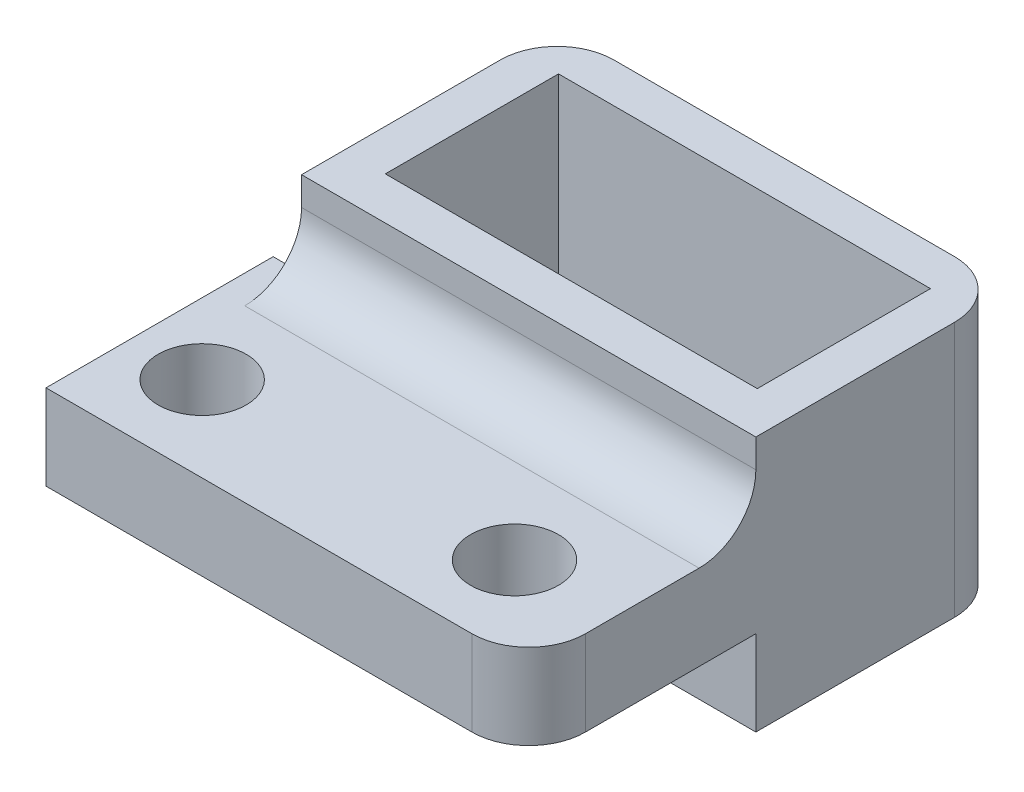
from build123d import *

# Parameters (mm, degrees)
CROQUIS1_W              = 18
CROQUIS1_H              = 18
CROQUIS1_R              = 1.55
SALIENTE_EXTRUIR1_DEPTH = 3
CROQUIS3_W              = 18
CROQUIS3_H              = 10
SALIENTE_EXTRUIR3_DEPTH = 3
CROQUIS4_W              = 2
CROQUIS4_H              = 10
CORTAR_EXTRUIR1_DEPTH   = 6
CROQUIS7_W              = 13.1
CROQUIS7_H              = 6.1
CORTAR_EXTRUIR2_DEPTH   = 6
CROQUIS9_W              = 16
CROQUIS9_H              = 10
CROQUIS9_W_2            = 13.1
CROQUIS9_H_2            = 6.1
SALIENTE_EXTRUIR4_DEPTH = 3
CROQUIS10_W             = 13.1
CROQUIS10_H             = 6.1
CROQUIS10_W_2           = 11.6
CROQUIS10_H_2           = 4.6
SALIENTE_EXTRUIR6_DEPTH = 2.5
CROQUIS11_W             = 16
CROQUIS11_H             = 1
CORTAR_EXTRUIR4_DEPTH   = 9
REDONDEO1_R             = 2
CROQUIS12_W             = 8
CROQUIS12_H             = 3
CORTAR_EXTRUIR5_DEPTH   = 1
REDONDEO2_R             = 2


with BuildPart() as part:
    # Croquis1 → Saliente-Extruir1 (new body)
    with BuildSketch(Plane(origin=(0, 0, 0), x_dir=(1, 0, 0), z_dir=(0, 1, 0))):
        with Locations((9, 9)):
            Rectangle(CROQUIS1_W, CROQUIS1_H)
        with Locations((3.5, 3)):
            Circle(CROQUIS1_R, mode=Mode.SUBTRACT)
        with Locations((14.5, 3)):
            Circle(CROQUIS1_R, mode=Mode.SUBTRACT)
    extrude(amount=SALIENTE_EXTRUIR1_DEPTH)

    # Croquis3 → Saliente-Extruir3 (add)
    with BuildSketch(Plane(origin=(0, 3, 0), x_dir=(1, 0, 0), z_dir=(0, 1, 0))):
        with Locations((9, 13)):
            Rectangle(CROQUIS3_W, CROQUIS3_H)
    extrude(amount=SALIENTE_EXTRUIR3_DEPTH)

    # Croquis4 → Cortar-Extruir1 (cut)
    with BuildSketch(Plane.XZ):
        with Locations((1, -13)):
            Rectangle(CROQUIS4_W, CROQUIS4_H)
    extrude(amount=-CORTAR_EXTRUIR1_DEPTH, mode=Mode.SUBTRACT)

    # Croquis7 → Cortar-Extruir2 (cut)
    with BuildSketch(Plane(origin=(0, 6, 0), x_dir=(1, 0, 0), z_dir=(0, 1, 0))):
        with Locations((10, 12.55)):
            Rectangle(CROQUIS7_W, CROQUIS7_H)
    extrude(amount=-CORTAR_EXTRUIR2_DEPTH, mode=Mode.SUBTRACT)

    # Croquis9 → Saliente-Extruir4 (add)
    with BuildSketch(Plane.XZ):
        with Locations((10, -13)):
            Rectangle(CROQUIS9_W, CROQUIS9_H)
        with Locations((10, -12.55)):
            Rectangle(CROQUIS9_W_2, CROQUIS9_H_2, mode=Mode.SUBTRACT)
    extrude(amount=SALIENTE_EXTRUIR4_DEPTH)

    # Croquis10 → Saliente-Extruir6 (add)
    with BuildSketch(Plane.XZ.offset(3)):
        with Locations((10, -12.55)):
            Rectangle(CROQUIS10_W, CROQUIS10_H)
        with Locations((10, -12.55)):
            Rectangle(CROQUIS10_W_2, CROQUIS10_H_2, mode=Mode.SUBTRACT)
    extrude(amount=-SALIENTE_EXTRUIR6_DEPTH)

    # Croquis11 → Cortar-Extruir4 (cut)
    with BuildSketch(Plane(origin=(0, 6, 0), x_dir=(1, 0, 0), z_dir=(0, 1, 0))):
        with Locations((10, 17.5)):
            Rectangle(CROQUIS11_W, CROQUIS11_H)
    extrude(amount=-CORTAR_EXTRUIR4_DEPTH, mode=Mode.SUBTRACT)

    # Redondeo1
    redondeo1_edges = [part.edges().sort_by_distance(p)[0] for p in [
        (18, 1.5, -17),
        (2, 1.5, -17),
        (18, 1.5, 0),
    ]]
    fillet(redondeo1_edges, radius=REDONDEO1_R)

    # Croquis12 → Cortar-Extruir5 (cut)
    with BuildSketch(Plane.ZY):
        with Locations((-4, 1.5)):
            Rectangle(CROQUIS12_W, CROQUIS12_H)
    extrude(amount=-CORTAR_EXTRUIR5_DEPTH, mode=Mode.SUBTRACT)

    # Redondeo2
    redondeo2_edges = [part.edges().sort_by_distance(p)[0] for p in [
        (10, 3, -8),
    ]]
    fillet(redondeo2_edges, radius=REDONDEO2_R)


solid = part.part
